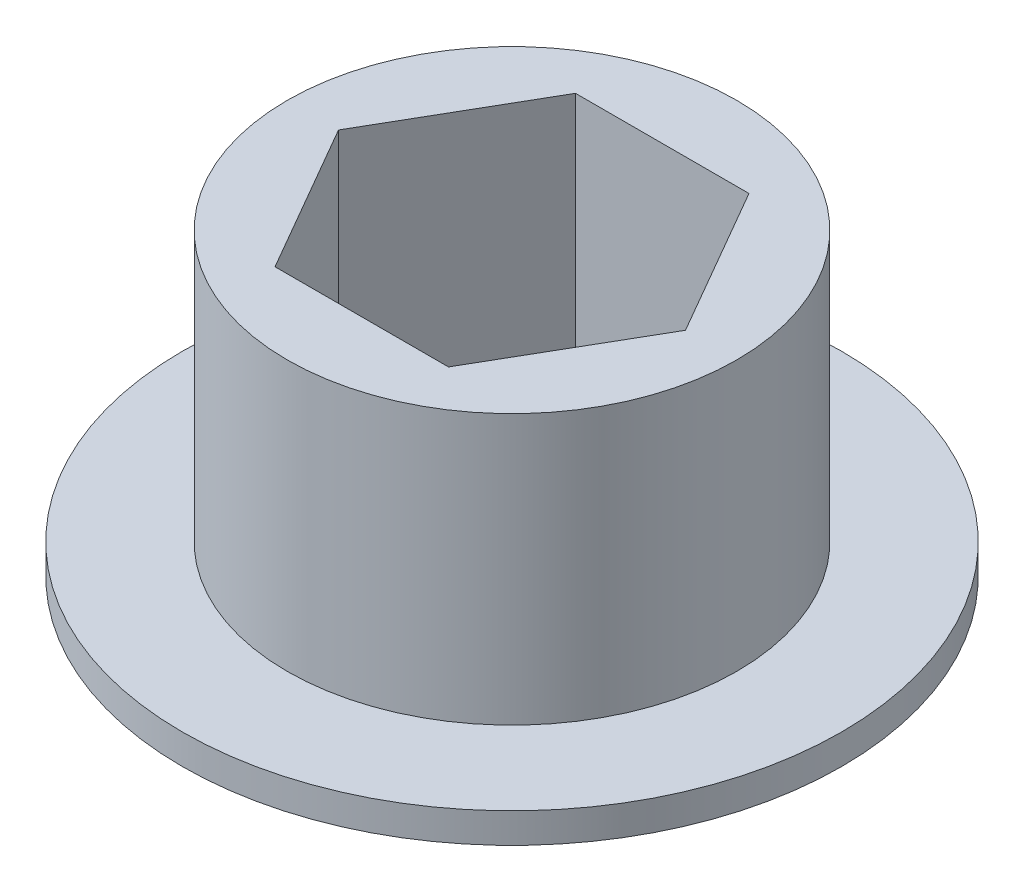
from build123d import *

# Parameters (mm, degrees)
SKETCH1_R           = 7.5
BOSS_EXTRUDE1_DEPTH = 5
BOSS_EXTRUDE2_START = -1
SKETCH2_R           = 11
SKETCH2_R_2         = 7.5
BOSS_EXTRUDE2_DEPTH = 1


with BuildPart() as part:
    # Sketch1 → Boss-Extrude1 (new, symmetric)
    with BuildSketch(Plane(origin=(0, 0, 0), x_dir=(1, 0, 0), z_dir=(0, 1, 0))):
        Circle(SKETCH1_R)
        Polygon((-2.893968224, -5.0125), (2.893968224, -5.0125), (5.787936449, 0), (2.893968224, 5.0125), (-2.893968224, 5.0125), (-5.787936449, 0), align=None, mode=Mode.SUBTRACT)
    extrude(amount=BOSS_EXTRUDE1_DEPTH, both=True)

    # Sketch2 → Boss-Extrude2 (add)
    with BuildSketch(Plane.XZ.offset(5).offset(BOSS_EXTRUDE2_START)):
        Circle(SKETCH2_R)
        Circle(SKETCH2_R_2, mode=Mode.SUBTRACT)
    extrude(amount=BOSS_EXTRUDE2_DEPTH)


solid = part.part
